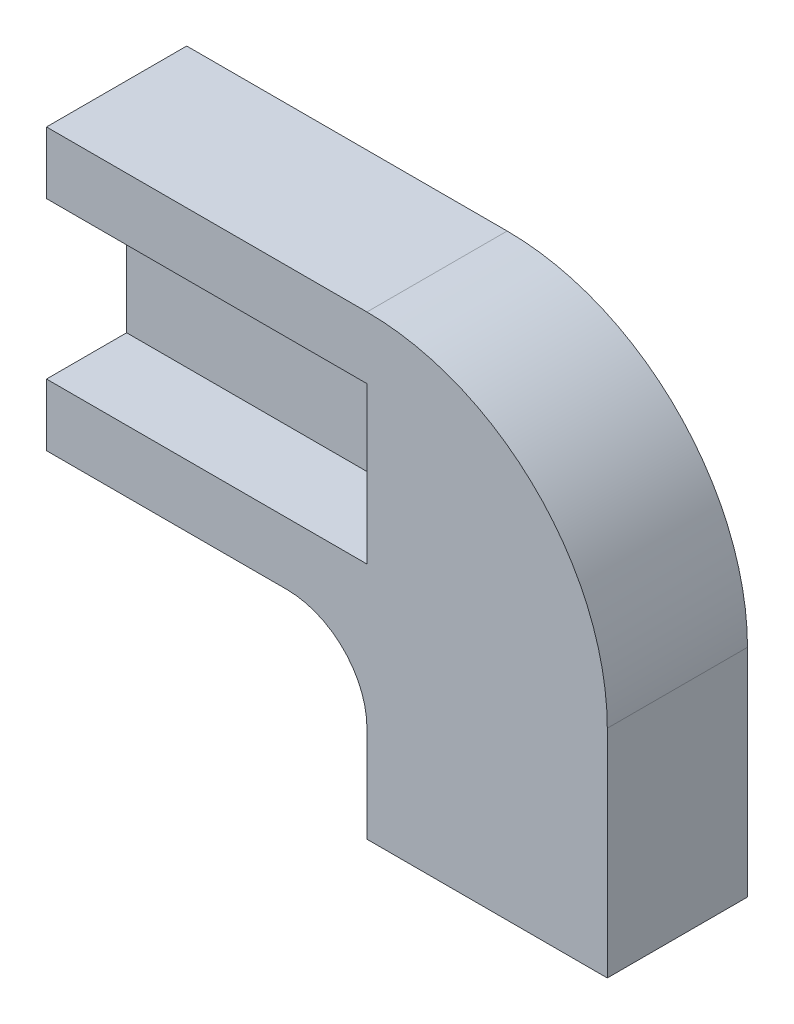
from build123d import *

# Parameters (mm, degrees)
BOSS_EXTRUDE1_DEPTH = 4.445
SKETCH2_W           = 10.16
SKETCH2_H           = 4.953
CUT_EXTRUDE1_DEPTH  = 2.54
FILLET1_R           = 2.54
FILLET2_R           = 7.62


with BuildPart() as part:
    # Sketch1 → Boss-Extrude1 (new body)
    with BuildSketch(Plane.XY):
        Polygon((0, 0), (17.78, 0), (17.78, -14.478), (10.16, -14.478), (10.16, -8.89), (0, -8.89), align=None)
    extrude(amount=BOSS_EXTRUDE1_DEPTH)

    # Sketch2 → Cut-Extrude1 (cut)
    with BuildSketch(Plane.XY.offset(4.445)):
        with Locations((5.08, -4.445)):
            Rectangle(SKETCH2_W, SKETCH2_H)
    extrude(amount=-CUT_EXTRUDE1_DEPTH, mode=Mode.SUBTRACT)

    # Fillet1
    fillet1_edges = [part.edges().sort_by_distance(p)[0] for p in [
        (10.16, -8.89, 2.2225),
    ]]
    fillet(fillet1_edges, radius=FILLET1_R)

    # Fillet2
    fillet2_edges = [part.edges().sort_by_distance(p)[0] for p in [
        (17.78, 0, 2.2225),
    ]]
    fillet(fillet2_edges, radius=FILLET2_R)


solid = part.part
